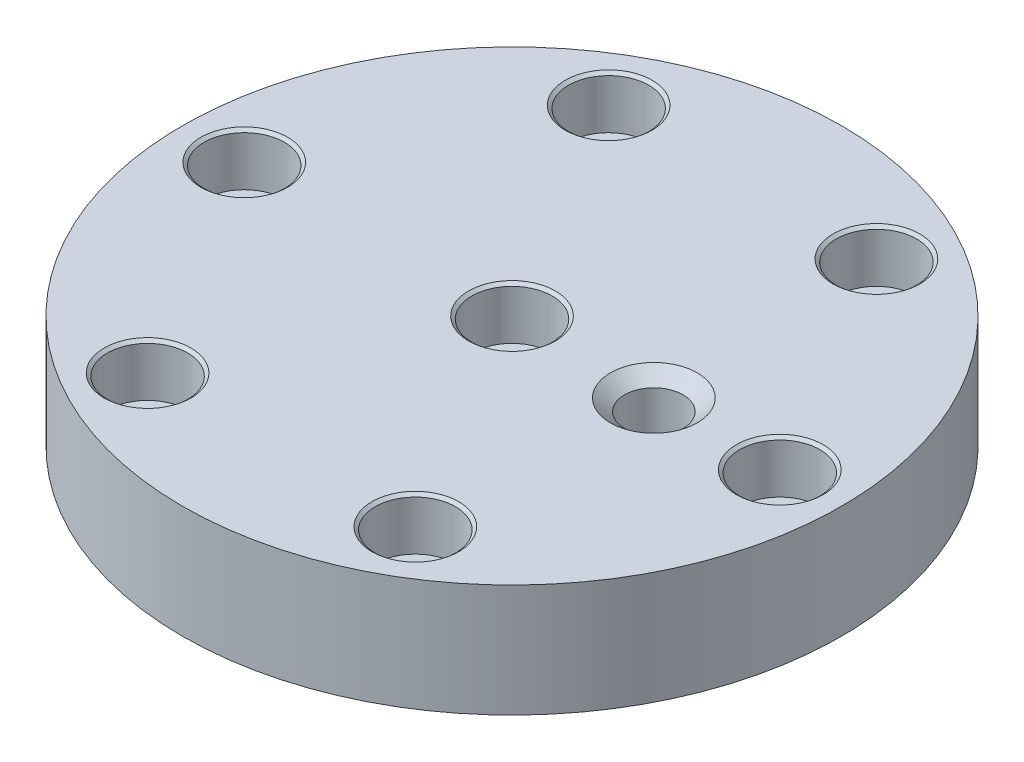
from build123d import *

# Parameters (mm, degrees)
SKETCH1_R                                   = 79
SKETCH1_R_2                                 = 6
BOSS_EXTRUDE1_DEPTH                         = 27
CBORE_FOR_0_BINDING_HEAD_MACHINE_SC_2_COUNT = 2
CBORE_FOR_0_BINDING_HEAD_MACHINE_SC_2_PITCH = 64
CBORE_FOR_0_BINDING_HEAD_MACHINE_SC_3_COUNT = 2
CBORE_FOR_0_BINDING_HEAD_MACHINE_SC_3_PITCH = 110.851251684
CBORE_FOR_0_BINDING_HEAD_MACHINE_SC_4_COUNT = 2
CBORE_FOR_0_BINDING_HEAD_MACHINE_SC_4_PITCH = 128
CBORE_FOR_0_BINDING_HEAD_MACHINE_SC_5_COUNT = 2
CBORE_FOR_0_BINDING_HEAD_MACHINE_SC_5_PITCH = 110.851251684
CBORE_FOR_0_BINDING_HEAD_MACHINE_SC_6_COUNT = 2
CBORE_FOR_0_BINDING_HEAD_MACHINE_SC_6_PITCH = 64
CBORE_FOR_0_BINDING_HEAD_MACHINE_SC_7_COUNT = 2
CBORE_FOR_0_BINDING_HEAD_MACHINE_SC_7_PITCH = 64
F_97_0_0059_DIAMETER_HOLE1_D                = 13.99999994
F_97_0_0059_DIAMETER_HOLE1_DEPTH            = 17
F_97_0_0059_DIAMETER_HOLE1_CSINK_D          = 20.8026
F_97_0_0059_DIAMETER_HOLE1_CSINK_ANGLE      = 100
F_97_0_0059_DIAMETER_HOLE1_TIP              = 4.206024315


with BuildPart() as part:
    # Sketch1 → Boss-Extrude1 (new body)
    with BuildSketch(Plane(origin=(0, 0, 0), x_dir=(1, 0, 0), z_dir=(0, 1, 0))):
        Circle(SKETCH1_R)
        Circle(SKETCH1_R_2, mode=Mode.SUBTRACT)
    extrude(amount=BOSS_EXTRUDE1_DEPTH)

    # Sketch5 → CBORE for #0 Binding Head Machine Screw1 (revolve, cut)
    with BuildSketch(Plane(origin=(31.838574382, 27, -55.51851206), x_dir=(0, 0, 1), z_dir=(1, 0, 0))):
        Polygon((0, 0), (0, 27), (6.249999946, 27), (6.249999946, 12.499999892), (9.625000054, 12.499999892), (9.625000054, 0.651392998), (10.4013, 0), align=None)
    cbore_for_0_binding_head_machine_screw1 = revolve(axis=Axis((31.838574382, 33.35, -55.51851206), (0, -1, 0)), mode=Mode.SUBTRACT)

    # CBORE for _0 Binding Head Machine Sc 2: CBORE for #0 Binding Head Machine Screw1 ×2
    with Locations(*[Vector(0.502518041, 0, 0.864566723) * (i * CBORE_FOR_0_BINDING_HEAD_MACHINE_SC_2_PITCH) for i in range(1, CBORE_FOR_0_BINDING_HEAD_MACHINE_SC_2_COUNT)]):
        add(cbore_for_0_binding_head_machine_screw1, mode=Mode.SUBTRACT)

    # CBORE for _0 Binding Head Machine Sc 3: CBORE for #0 Binding Head Machine Screw1 ×2
    with Locations(*[Vector(0.002910028, 0, 0.999995766) * (i * CBORE_FOR_0_BINDING_HEAD_MACHINE_SC_3_PITCH) for i in range(1, CBORE_FOR_0_BINDING_HEAD_MACHINE_SC_3_COUNT)]):
        add(cbore_for_0_binding_head_machine_screw1, mode=Mode.SUBTRACT)

    # CBORE for _0 Binding Head Machine Sc 4: CBORE for #0 Binding Head Machine Screw1 ×2
    with Locations(*[Vector(-0.497477725, 0, 0.867476751) * (i * CBORE_FOR_0_BINDING_HEAD_MACHINE_SC_4_PITCH) for i in range(1, CBORE_FOR_0_BINDING_HEAD_MACHINE_SC_4_COUNT)]):
        add(cbore_for_0_binding_head_machine_screw1, mode=Mode.SUBTRACT)

    # CBORE for _0 Binding Head Machine Sc 5: CBORE for #0 Binding Head Machine Screw1 ×2
    with Locations(*[Vector(-0.864566723, 0, 0.502518041) * (i * CBORE_FOR_0_BINDING_HEAD_MACHINE_SC_5_PITCH) for i in range(1, CBORE_FOR_0_BINDING_HEAD_MACHINE_SC_5_COUNT)]):
        add(cbore_for_0_binding_head_machine_screw1, mode=Mode.SUBTRACT)

    # CBORE for _0 Binding Head Machine Sc 6: CBORE for #0 Binding Head Machine Screw1 ×2
    with Locations(*[Vector(-0.999995766, 0, 0.002910028) * (i * CBORE_FOR_0_BINDING_HEAD_MACHINE_SC_6_PITCH) for i in range(1, CBORE_FOR_0_BINDING_HEAD_MACHINE_SC_6_COUNT)]):
        add(cbore_for_0_binding_head_machine_screw1, mode=Mode.SUBTRACT)

    # CBORE for _0 Binding Head Machine Sc 7: CBORE for #0 Binding Head Machine Screw1 ×2
    with Locations(*[Vector(-0.497477725, 0, 0.867476751) * (i * CBORE_FOR_0_BINDING_HEAD_MACHINE_SC_7_PITCH) for i in range(1, CBORE_FOR_0_BINDING_HEAD_MACHINE_SC_7_COUNT)]):
        add(cbore_for_0_binding_head_machine_screw1, mode=Mode.SUBTRACT)

    # #97 (0.0059) Diameter Hole1
    with Locations(Plane(origin=(0, 27, 0), x_dir=(1, 0, 0), z_dir=(0, 1, 0))):
        with Locations((34, 0)):
            CounterSinkHole(F_97_0_0059_DIAMETER_HOLE1_D / 2, F_97_0_0059_DIAMETER_HOLE1_CSINK_D / 2, depth=F_97_0_0059_DIAMETER_HOLE1_DEPTH, counter_sink_angle=F_97_0_0059_DIAMETER_HOLE1_CSINK_ANGLE)
            with Locations((0, 0, -(F_97_0_0059_DIAMETER_HOLE1_DEPTH + F_97_0_0059_DIAMETER_HOLE1_TIP / 2))):  # 118° drill point
                Cone(0, F_97_0_0059_DIAMETER_HOLE1_D / 2, F_97_0_0059_DIAMETER_HOLE1_TIP, mode=Mode.SUBTRACT)


solid = part.part
